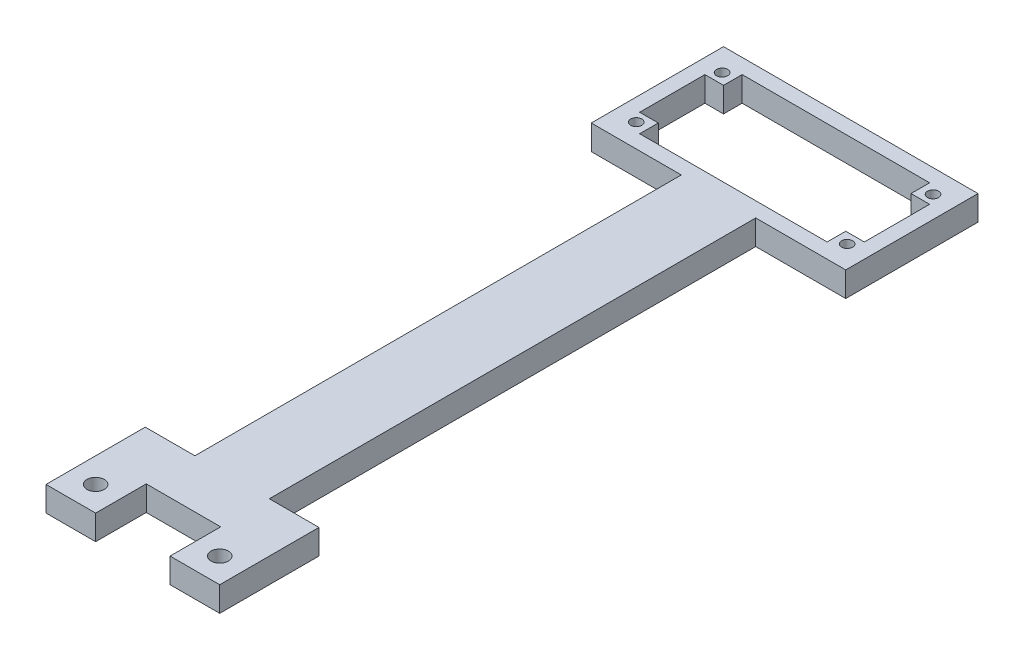
from build123d import *

# Parameters (mm, degrees)
SKETCH2_W           = 51.27
SKETCH2_H           = 26.65
BOSS_EXTRUDE2_DEPTH = 5
SKETCH3_W           = 45.27
SKETCH3_H           = 20.65
CUT_EXTRUDE1_DEPTH  = 6
SKETCH4_W           = 3.75
SKETCH4_H           = 3.75
BOSS_EXTRUDE3_DEPTH = 5
SKETCH5_R           = 1.12
CUT_EXTRUDE2_DEPTH  = 6
SKETCH6_W           = 15
SKETCH6_H           = 108
BOSS_EXTRUDE4_DEPTH = 5
SKETCH7_W           = 10
SKETCH7_H           = 20
BOSS_EXTRUDE5_DEPTH = 5
SKETCH8_R           = 1.75
CUT_EXTRUDE3_DEPTH  = 6
SKETCH9_W           = 15
SKETCH9_H           = 0.2
CUT_EXTRUDE4_DEPTH  = 6


with BuildPart() as part:
    # Sketch2 → Boss-Extrude2 (new body)
    with BuildSketch(Plane(origin=(0, 0, 0), x_dir=(1, 0, 0), z_dir=(0, 1, 0))):
        with Locations((22.635, 10.325)):
            Rectangle(SKETCH2_W, SKETCH2_H)
    extrude(amount=BOSS_EXTRUDE2_DEPTH)

    # Sketch3 → Cut-Extrude1 (cut, through all)
    with BuildSketch(Plane(origin=(0, 5, 0), x_dir=(1, 0, 0), z_dir=(0, 1, 0))):
        with Locations((22.635, 10.325)):
            Rectangle(SKETCH3_W, SKETCH3_H)
    extrude(amount=-CUT_EXTRUDE1_DEPTH, mode=Mode.SUBTRACT)

    # Sketch4 → Boss-Extrude3 (add)
    with BuildSketch(Plane(origin=(0, 5, 0), x_dir=(1, 0, 0), z_dir=(0, 1, 0))):
        with Locations((1.875, 18.775)):
            Rectangle(SKETCH4_W, SKETCH4_H)
        with Locations((1.875, 1.875)):
            Rectangle(SKETCH4_W, SKETCH4_H)
        with Locations((43.395, 1.875)):
            Rectangle(SKETCH4_W, SKETCH4_H)
        with Locations((43.395, 18.775)):
            Rectangle(SKETCH4_W, SKETCH4_H)
    extrude(amount=-BOSS_EXTRUDE3_DEPTH)

    # Sketch5 → Cut-Extrude2 (cut, through all)
    with BuildSketch(Plane(origin=(0, 5, 0), x_dir=(1, 0, 0), z_dir=(0, 1, 0))):
        with Locations((1.385, 18.975)):
            Circle(SKETCH5_R)
        with Locations((43.885, 18.975)):
            Circle(SKETCH5_R)
        with Locations((43.885, 1.675)):
            Circle(SKETCH5_R)
        with Locations((1.385, 1.675)):
            Circle(SKETCH5_R)
    extrude(amount=-CUT_EXTRUDE2_DEPTH, mode=Mode.SUBTRACT)

    # Sketch6 → Boss-Extrude4 (add)
    with BuildSketch(Plane(origin=(0, 5, 0), x_dir=(1, 0, 0), z_dir=(0, 1, 0))):
        with Locations((22.635, -57)):
            Rectangle(SKETCH6_W, SKETCH6_H)
    extrude(amount=-BOSS_EXTRUDE4_DEPTH)

    # Sketch7 → Boss-Extrude5 (add)
    with BuildSketch(Plane(origin=(0, 5, 0), x_dir=(1, 0, 0), z_dir=(0, 1, 0))):
        with Locations((35.135, -111)):
            Rectangle(SKETCH7_W, SKETCH7_H)
        with Locations((10.135, -111)):
            Rectangle(SKETCH7_W, SKETCH7_H)
    extrude(amount=-BOSS_EXTRUDE5_DEPTH)

    # Sketch8 → Cut-Extrude3 (cut, through all)
    with BuildSketch(Plane(origin=(0, 5, 0), x_dir=(1, 0, 0), z_dir=(0, 1, 0))):
        with Locations((10.135, -116)):
            Circle(SKETCH8_R)
        with Locations((35.135, -116)):
            Circle(SKETCH8_R)
    extrude(amount=-CUT_EXTRUDE3_DEPTH, mode=Mode.SUBTRACT)

    # Sketch9 → Cut-Extrude4 (cut, through all)
    with BuildSketch(Plane(origin=(0, 5, 0), x_dir=(1, 0, 0), z_dir=(0, 1, 0))):
        with Locations((22.635, -110.9)):
            Rectangle(SKETCH9_W, SKETCH9_H)
    extrude(amount=-CUT_EXTRUDE4_DEPTH, mode=Mode.SUBTRACT)


solid = part.part
